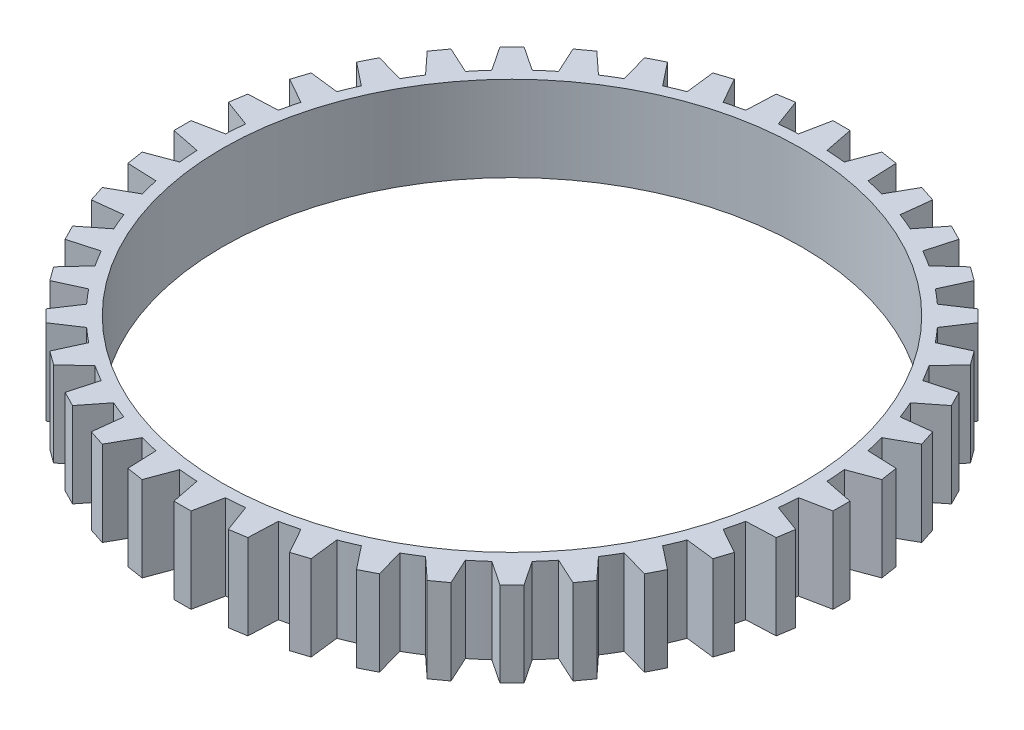
from build123d import *

# Parameters (mm, degrees)
BOSS_EXTRUDE1_DEPTH     = 15
SKETCH4_R               = 51
CUT_EXTRUDE1_DEPTH      = 1
CUT_EXTRUDE1_DEPTH_BACK = 16


with BuildPart() as part:
    # Sketch1 → Boss-Extrude1 (new body)
    with BuildSketch(Plane(origin=(0, 0, 0), x_dir=(1, 0, 0), z_dir=(0, 1, 0))):
        with BuildLine():
            Line((-2.511911789, 52.940441056), (-1.5, 58))
            Line((-1.5, 58), (1.5, 58))
            Line((1.5, 58), (2.511911789, 52.940441056))
            ThreePointArc((2.511911789, 52.940441056), (4.158332074, 52.836618688), (5.800723589, 52.681605954))
            Line((5.800723589, 52.681605954), (7.591666461, 57.520575452))
            Line((7.591666461, 57.520575452), (10.554731483, 57.051272057))
            Line((10.554731483, 57.051272057), (10.762695562, 51.8957068))
            ThreePointArc((10.762695562, 51.8957068), (12.372604284, 51.535605781), (13.970525901, 51.125574873))
            Line((13.970525901, 51.125574873), (16.496400899, 55.624803437))
            Line((16.496400899, 55.624803437), (19.349570448, 54.697752454))
            Line((19.349570448, 54.697752454), (18.748466051, 49.57312801))
            ThreePointArc((18.748466051, 49.57312801), (20.282221915, 48.965615223), (21.796327499, 48.310662462))
            Line((21.796327499, 48.310662462), (24.994939199, 52.359364153))
            Line((24.994939199, 52.359364153), (27.667958771, 50.997392653))
            Line((27.667958771, 50.997392653), (26.272587083, 46.029894286))
            ThreePointArc((26.272587083, 46.029894286), (27.69242393, 45.189928711), (29.085431177, 44.306181208))
            Line((29.085431177, 44.306181208), (32.878019141, 47.804663552))
            Line((32.878019141, 47.804663552), (35.305070125, 46.041307795))
            Line((35.305070125, 46.041307795), (33.149789828, 41.353251799))
            ThreePointArc((33.149789828, 41.353251799), (34.420746562, 40.301516177), (35.65835501, 39.210734729))
            Line((35.65835501, 39.210734729), (39.951533137, 42.072853481))
            Line((39.951533137, 42.072853481), (42.072853481, 39.951533137))
            Line((42.072853481, 39.951533137), (39.210734729, 35.65835501))
            ThreePointArc((39.210734729, 35.65835501), (40.301516177, 34.420746561), (41.353251799, 33.149789828))
            Line((41.353251799, 33.149789828), (46.041307795, 35.305070125))
            Line((46.041307795, 35.305070125), (47.804663552, 32.878019141))
            Line((47.804663552, 32.878019141), (44.306181208, 29.085431177))
            ThreePointArc((44.306181208, 29.085431177), (45.189928711, 27.69242393), (46.029894286, 26.272587083))
            Line((46.029894286, 26.272587083), (50.997392653, 27.667958771))
            Line((50.997392653, 27.667958771), (52.359364153, 24.994939199))
            Line((52.359364153, 24.994939199), (48.310662462, 21.796327499))
            ThreePointArc((48.310662462, 21.796327499), (48.965615223, 20.282221915), (49.57312801, 18.748466051))
            Line((49.57312801, 18.748466051), (54.697752454, 19.349570448))
            Line((54.697752454, 19.349570448), (55.624803437, 16.496400899))
            Line((55.624803437, 16.496400899), (51.125574873, 13.970525901))
            ThreePointArc((51.125574873, 13.970525901), (51.535605781, 12.372604284), (51.8957068, 10.762695562))
            Line((51.8957068, 10.762695562), (57.051272057, 10.554731483))
            Line((57.051272057, 10.554731483), (57.520575452, 7.591666461))
            Line((57.520575452, 7.591666461), (52.681605954, 5.800723589))
            ThreePointArc((52.681605954, 5.800723589), (52.836618688, 4.158332074), (52.940441056, 2.511911789))
            Line((52.940441056, 2.511911789), (58, 1.5))
            Line((58, 1.5), (58, -1.5))
            Line((58, -1.5), (52.940441056, -2.511911789))
            ThreePointArc((52.940441056, -2.511911789), (52.836618688, -4.158332074), (52.681605954, -5.800723589))
            Line((52.681605954, -5.800723589), (57.520575452, -7.591666461))
            Line((57.520575452, -7.591666461), (57.051272057, -10.554731483))
            Line((57.051272057, -10.554731483), (51.8957068, -10.762695562))
            ThreePointArc((51.8957068, -10.762695562), (51.535605781, -12.372604284), (51.125574873, -13.970525901))
            Line((51.125574873, -13.970525901), (55.624803437, -16.496400899))
            Line((55.624803437, -16.496400899), (54.697752454, -19.349570448))
            Line((54.697752454, -19.349570448), (49.57312801, -18.748466051))
            ThreePointArc((49.57312801, -18.748466051), (48.965615223, -20.282221915), (48.310662462, -21.796327499))
            Line((48.310662462, -21.796327499), (52.359364153, -24.994939199))
            Line((52.359364153, -24.994939199), (50.997392653, -27.667958771))
            Line((50.997392653, -27.667958771), (46.029894286, -26.272587083))
            ThreePointArc((46.029894286, -26.272587083), (45.189928711, -27.69242393), (44.306181208, -29.085431177))
            Line((44.306181208, -29.085431177), (47.804663552, -32.878019141))
            Line((47.804663552, -32.878019141), (46.041307795, -35.305070125))
            Line((46.041307795, -35.305070125), (41.353251799, -33.149789828))
            ThreePointArc((41.353251799, -33.149789828), (40.301516177, -34.420746562), (39.210734729, -35.65835501))
            Line((39.210734729, -35.65835501), (42.072853481, -39.951533137))
            Line((42.072853481, -39.951533137), (39.951533137, -42.072853481))
            Line((39.951533137, -42.072853481), (35.65835501, -39.210734729))
            ThreePointArc((35.65835501, -39.210734729), (34.420746561, -40.301516177), (33.149789828, -41.353251799))
            Line((33.149789828, -41.353251799), (35.305070125, -46.041307795))
            Line((35.305070125, -46.041307795), (32.878019141, -47.804663552))
            Line((32.878019141, -47.804663552), (29.085431177, -44.306181208))
            ThreePointArc((29.085431177, -44.306181208), (27.69242393, -45.189928711), (26.272587083, -46.029894286))
            Line((26.272587083, -46.029894286), (27.667958771, -50.997392653))
            Line((27.667958771, -50.997392653), (24.994939199, -52.359364153))
            Line((24.994939199, -52.359364153), (21.796327499, -48.310662462))
            ThreePointArc((21.796327499, -48.310662462), (20.282221915, -48.965615223), (18.748466051, -49.57312801))
            Line((18.748466051, -49.57312801), (19.349570448, -54.697752454))
            Line((19.349570448, -54.697752454), (16.496400899, -55.624803437))
            Line((16.496400899, -55.624803437), (13.970525901, -51.125574873))
            ThreePointArc((13.970525901, -51.125574873), (12.372604284, -51.535605781), (10.762695562, -51.8957068))
            Line((10.762695562, -51.8957068), (10.554731483, -57.051272057))
            Line((10.554731483, -57.051272057), (7.591666461, -57.520575452))
            Line((7.591666461, -57.520575452), (5.800723589, -52.681605954))
            ThreePointArc((5.800723589, -52.681605954), (4.158332074, -52.836618688), (2.511911789, -52.940441056))
            Line((2.511911789, -52.940441056), (1.5, -58))
            Line((1.5, -58), (-1.5, -58))
            Line((-1.5, -58), (-2.511911789, -52.940441056))
            ThreePointArc((-2.511911789, -52.940441056), (-4.158332074, -52.836618688), (-5.800723589, -52.681605954))
            Line((-5.800723589, -52.681605954), (-7.591666461, -57.520575452))
            Line((-7.591666461, -57.520575452), (-10.554731483, -57.051272057))
            Line((-10.554731483, -57.051272057), (-10.762695562, -51.8957068))
            ThreePointArc((-10.762695562, -51.8957068), (-12.372604284, -51.535605781), (-13.970525901, -51.125574873))
            Line((-13.970525901, -51.125574873), (-16.496400899, -55.624803437))
            Line((-16.496400899, -55.624803437), (-19.349570448, -54.697752454))
            Line((-19.349570448, -54.697752454), (-18.748466051, -49.57312801))
            ThreePointArc((-18.748466051, -49.57312801), (-20.282221915, -48.965615223), (-21.796327499, -48.310662462))
            Line((-21.796327499, -48.310662462), (-24.994939199, -52.359364153))
            Line((-24.994939199, -52.359364153), (-27.667958771, -50.997392653))
            Line((-27.667958771, -50.997392653), (-26.272587083, -46.029894286))
            ThreePointArc((-26.272587083, -46.029894286), (-27.69242393, -45.189928711), (-29.085431177, -44.306181208))
            Line((-29.085431177, -44.306181208), (-32.878019141, -47.804663552))
            Line((-32.878019141, -47.804663552), (-35.305070125, -46.041307795))
            Line((-35.305070125, -46.041307795), (-33.149789828, -41.353251799))
            ThreePointArc((-33.149789828, -41.353251799), (-34.420746562, -40.301516177), (-35.65835501, -39.210734729))
            Line((-35.65835501, -39.210734729), (-39.951533137, -42.072853481))
            Line((-39.951533137, -42.072853481), (-42.072853481, -39.951533137))
            Line((-42.072853481, -39.951533137), (-39.210734729, -35.65835501))
            ThreePointArc((-39.210734729, -35.65835501), (-40.301516177, -34.420746561), (-41.353251799, -33.149789828))
            Line((-41.353251799, -33.149789828), (-46.041307795, -35.305070125))
            Line((-46.041307795, -35.305070125), (-47.804663552, -32.878019141))
            Line((-47.804663552, -32.878019141), (-44.306181208, -29.085431177))
            ThreePointArc((-44.306181208, -29.085431177), (-45.189928711, -27.69242393), (-46.029894286, -26.272587083))
            Line((-46.029894286, -26.272587083), (-50.997392653, -27.667958771))
            Line((-50.997392653, -27.667958771), (-52.359364153, -24.994939199))
            Line((-52.359364153, -24.994939199), (-48.310662462, -21.796327499))
            ThreePointArc((-48.310662462, -21.796327499), (-48.965615223, -20.282221915), (-49.57312801, -18.748466051))
            Line((-49.57312801, -18.748466051), (-54.697752454, -19.349570448))
            Line((-54.697752454, -19.349570448), (-55.624803437, -16.496400899))
            Line((-55.624803437, -16.496400899), (-51.125574873, -13.970525901))
            ThreePointArc((-51.125574873, -13.970525901), (-51.535605781, -12.372604284), (-51.8957068, -10.762695562))
            Line((-51.8957068, -10.762695562), (-57.051272057, -10.554731483))
            Line((-57.051272057, -10.554731483), (-57.520575452, -7.591666461))
            Line((-57.520575452, -7.591666461), (-52.681605954, -5.800723589))
            ThreePointArc((-52.681605954, -5.800723589), (-52.836618688, -4.158332074), (-52.940441056, -2.511911789))
            Line((-52.940441056, -2.511911789), (-58, -1.5))
            Line((-58, -1.5), (-58, 1.5))
            Line((-58, 1.5), (-52.940441056, 2.511911789))
            ThreePointArc((-52.940441056, 2.511911789), (-52.836618688, 4.158332074), (-52.681605954, 5.800723589))
            Line((-52.681605954, 5.800723589), (-57.520575452, 7.591666461))
            Line((-57.520575452, 7.591666461), (-57.051272057, 10.554731483))
            Line((-57.051272057, 10.554731483), (-51.8957068, 10.762695562))
            ThreePointArc((-51.8957068, 10.762695562), (-51.535605781, 12.372604284), (-51.125574873, 13.970525901))
            Line((-51.125574873, 13.970525901), (-55.624803437, 16.496400899))
            Line((-55.624803437, 16.496400899), (-54.697752454, 19.349570448))
            Line((-54.697752454, 19.349570448), (-49.57312801, 18.748466051))
            ThreePointArc((-49.57312801, 18.748466051), (-48.965615223, 20.282221915), (-48.310662462, 21.796327499))
            Line((-48.310662462, 21.796327499), (-52.359364153, 24.994939199))
            Line((-52.359364153, 24.994939199), (-50.997392653, 27.667958771))
            Line((-50.997392653, 27.667958771), (-46.029894286, 26.272587083))
            ThreePointArc((-46.029894286, 26.272587083), (-45.189928711, 27.69242393), (-44.306181208, 29.085431177))
            Line((-44.306181208, 29.085431177), (-47.804663552, 32.878019141))
            Line((-47.804663552, 32.878019141), (-46.041307795, 35.305070125))
            Line((-46.041307795, 35.305070125), (-41.353251799, 33.149789828))
            ThreePointArc((-41.353251799, 33.149789828), (-40.301516177, 34.420746562), (-39.210734729, 35.65835501))
            Line((-39.210734729, 35.65835501), (-42.072853481, 39.951533137))
            Line((-42.072853481, 39.951533137), (-39.951533137, 42.072853481))
            Line((-39.951533137, 42.072853481), (-35.65835501, 39.210734729))
            ThreePointArc((-35.65835501, 39.210734729), (-34.420746561, 40.301516177), (-33.149789828, 41.353251799))
            Line((-33.149789828, 41.353251799), (-35.305070125, 46.041307795))
            Line((-35.305070125, 46.041307795), (-32.878019141, 47.804663552))
            Line((-32.878019141, 47.804663552), (-29.085431177, 44.306181208))
            ThreePointArc((-29.085431177, 44.306181208), (-27.69242393, 45.189928711), (-26.272587083, 46.029894286))
            Line((-26.272587083, 46.029894286), (-27.667958771, 50.997392653))
            Line((-27.667958771, 50.997392653), (-24.994939199, 52.359364153))
            Line((-24.994939199, 52.359364153), (-21.796327499, 48.310662462))
            ThreePointArc((-21.796327499, 48.310662462), (-20.282221915, 48.965615223), (-18.748466051, 49.57312801))
            Line((-18.748466051, 49.57312801), (-19.349570448, 54.697752454))
            Line((-19.349570448, 54.697752454), (-16.496400899, 55.624803437))
            Line((-16.496400899, 55.624803437), (-13.970525901, 51.125574873))
            ThreePointArc((-13.970525901, 51.125574873), (-12.372604284, 51.535605781), (-10.762695562, 51.8957068))
            Line((-10.762695562, 51.8957068), (-10.554731483, 57.051272057))
            Line((-10.554731483, 57.051272057), (-7.591666461, 57.520575452))
            Line((-7.591666461, 57.520575452), (-5.800723589, 52.681605954))
            ThreePointArc((-5.800723589, 52.681605954), (-4.158332074, 52.836618688), (-2.511911789, 52.940441056))
        make_face()
    extrude(amount=BOSS_EXTRUDE1_DEPTH)

    # Sketch4 → Cut-Extrude1 (cut, two sides)
    with BuildSketch(Plane(origin=(0, 15, 0), x_dir=(1, 0, 0), z_dir=(0, 1, 0))) as cut_extrude1_sk:
        Circle(SKETCH4_R)
    extrude(amount=CUT_EXTRUDE1_DEPTH, mode=Mode.SUBTRACT)
    extrude(cut_extrude1_sk.sketch, amount=-CUT_EXTRUDE1_DEPTH_BACK, mode=Mode.SUBTRACT)


solid = part.part
